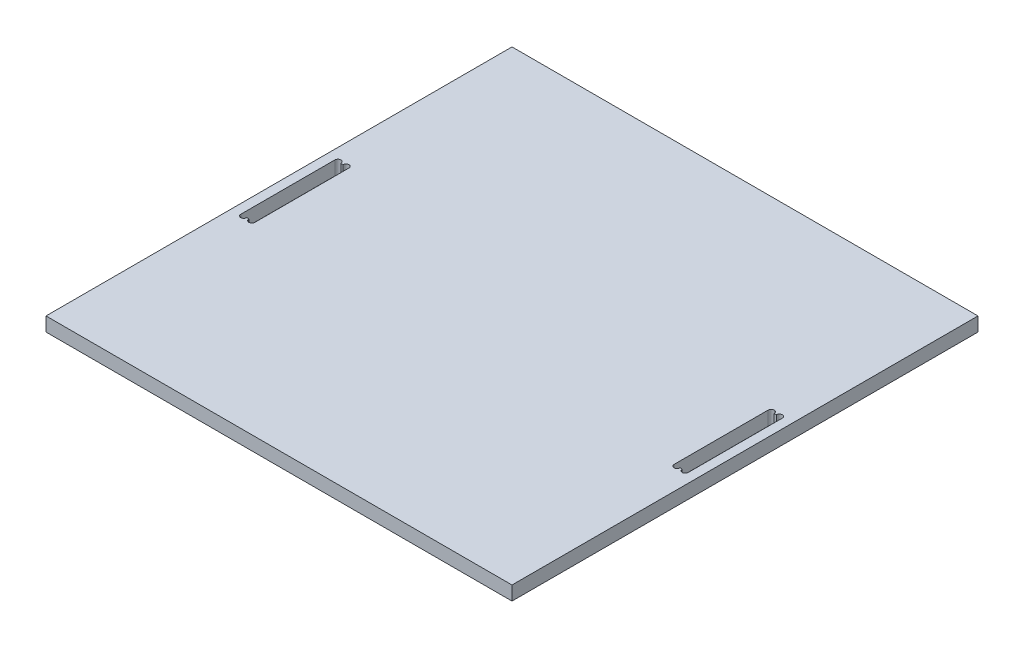
from build123d import *

# Parameters (mm, degrees)
CROQUIS1_W              = 500
CROQUIS1_H              = 500
SALIENTE_EXTRUIR1_DEPTH = 15
CROQUIS3_W              = 15.1
CROQUIS3_H              = 101
CORTAR_EXTRUIR1_DEPTH   = 16
CROQUIS4_R              = 3.2
CROQUIS4_R_2            = 3.175
CORTAR_EXTRUIR2_DEPTH   = 16


with BuildPart() as part:
    # Croquis1 → Saliente-Extruir1 (new body)
    with BuildSketch(Plane(origin=(0, 0, 0), x_dir=(1, 0, 0), z_dir=(0, 1, 0))):
        Rectangle(CROQUIS1_W, CROQUIS1_H)
    extrude(amount=SALIENTE_EXTRUIR1_DEPTH)

    # Croquis3 → Cortar-Extruir1 (cut, through all)
    with BuildSketch(Plane(origin=(0, 15, 0), x_dir=(1, 0, 0), z_dir=(0, 1, 0))):
        with Locations((-232.45, -0.5)):
            Rectangle(CROQUIS3_W, CROQUIS3_H)
        with Locations((232.45, -0.5)):
            Rectangle(CROQUIS3_W, CROQUIS3_H)
    extrude(amount=-CORTAR_EXTRUIR1_DEPTH, mode=Mode.SUBTRACT)

    # Croquis4 → Cortar-Extruir2 (cut, through all)
    with BuildSketch(Plane(origin=(0, 15, 0), x_dir=(1, 0, 0), z_dir=(0, 1, 0))):
        with Locations((-228.1, -51)):
            Circle(CROQUIS4_R)
        with Locations((-236.8, -51)):
            Circle(CROQUIS4_R)
        with Locations((-228.075, 50)):
            Circle(CROQUIS4_R_2)
        with Locations((-236.825, 50)):
            Circle(CROQUIS4_R_2)
        with Locations((236.8, -51)):
            Circle(CROQUIS4_R)
        with Locations((228.1, -51)):
            Circle(CROQUIS4_R)
        with Locations((228.075, 50)):
            Circle(CROQUIS4_R_2)
        with Locations((236.825, 50)):
            Circle(CROQUIS4_R_2)
    extrude(amount=-CORTAR_EXTRUIR2_DEPTH, mode=Mode.SUBTRACT)


solid = part.part
